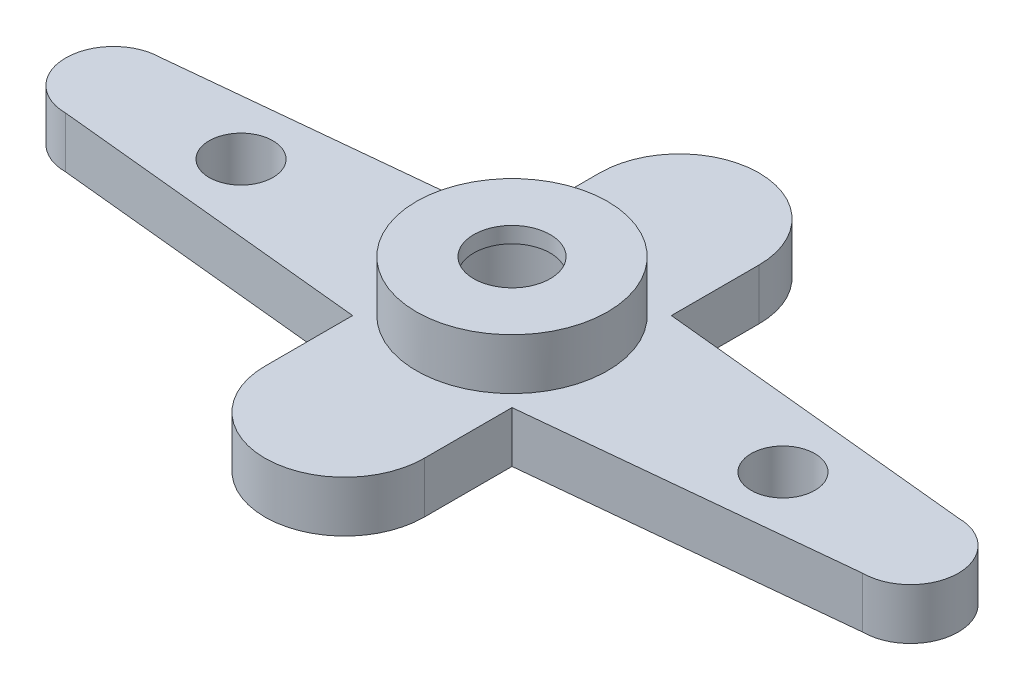
from build123d import *

# Parameters (mm, degrees)
SKETCH1_R           = 10
BOSS_EXTRUDE1_DEPTH = 4
SKETCH2_R           = 15
SKETCH2_R_2         = 10
BOSS_EXTRUDE2_DEPTH = 8
SKETCH3_R           = 5
CUT_EXTRUDE1_DEPTH  = 9
BOSS_EXTRUDE3_START = 9.5
SKETCH4_R           = 10
SKETCH4_R_2         = 6
BOSS_EXTRUDE3_DEPTH = 2.5


with BuildPart() as part:
    # Sketch1 → Boss-Extrude1 (new body, symmetric)
    with BuildSketch(Plane(origin=(0, 0, 0), x_dir=(1, 0, 0), z_dir=(0, 1, 0))):
        with BuildLine():
            Line((12.5, 12.5), (12.5, 26.25))
            ThreePointArc((12.5, 26.25), (0, 38.75), (-12.5, 26.25))
            Line((-12.5, 26.25), (-12.5, 12.5))
            Line((-12.5, 12.5), (-62.5, 7.5))
            ThreePointArc((-62.5, 7.5), (-70, 0), (-62.5, -7.5))
            Line((-62.5, -7.5), (-12.5, -12.5))
            Line((-12.5, -12.5), (-12.5, -26.25))
            ThreePointArc((-12.5, -26.25), (0, -38.75), (12.5, -26.25))
            Line((12.5, -26.25), (12.5, -12.5))
            Line((12.5, -12.5), (62.5, -7.5))
            ThreePointArc((62.5, -7.5), (70, 0), (62.5, 7.5))
            Line((62.5, 7.5), (12.5, 12.5))
        make_face()
        Circle(SKETCH1_R, mode=Mode.SUBTRACT)
    extrude(amount=BOSS_EXTRUDE1_DEPTH, both=True)

    # Sketch2 → Boss-Extrude2 (add)
    with BuildSketch(Plane(origin=(0, 4, 0), x_dir=(1, 0, 0), z_dir=(0, 1, 0))):
        Circle(SKETCH2_R)
        Circle(SKETCH2_R_2, mode=Mode.SUBTRACT)
    extrude(amount=BOSS_EXTRUDE2_DEPTH)

    # Sketch3 → Cut-Extrude1 (cut, through all)
    with BuildSketch(Plane(origin=(0, 4, 0), x_dir=(1, 0, 0), z_dir=(0, 1, 0))):
        with Locations((42.5, 0)):
            Circle(SKETCH3_R)
        with Locations((-42.5, 0)):
            Circle(SKETCH3_R)
    extrude(amount=-CUT_EXTRUDE1_DEPTH, mode=Mode.SUBTRACT)

    # Sketch4 → Boss-Extrude3 (add)
    with BuildSketch(Plane(origin=(0, 0, 0), x_dir=(1, 0, 0), z_dir=(0, 1, 0)).offset(BOSS_EXTRUDE3_START)):
        Circle(SKETCH4_R)
        Circle(SKETCH4_R_2, mode=Mode.SUBTRACT)
    extrude(amount=BOSS_EXTRUDE3_DEPTH)


solid = part.part
